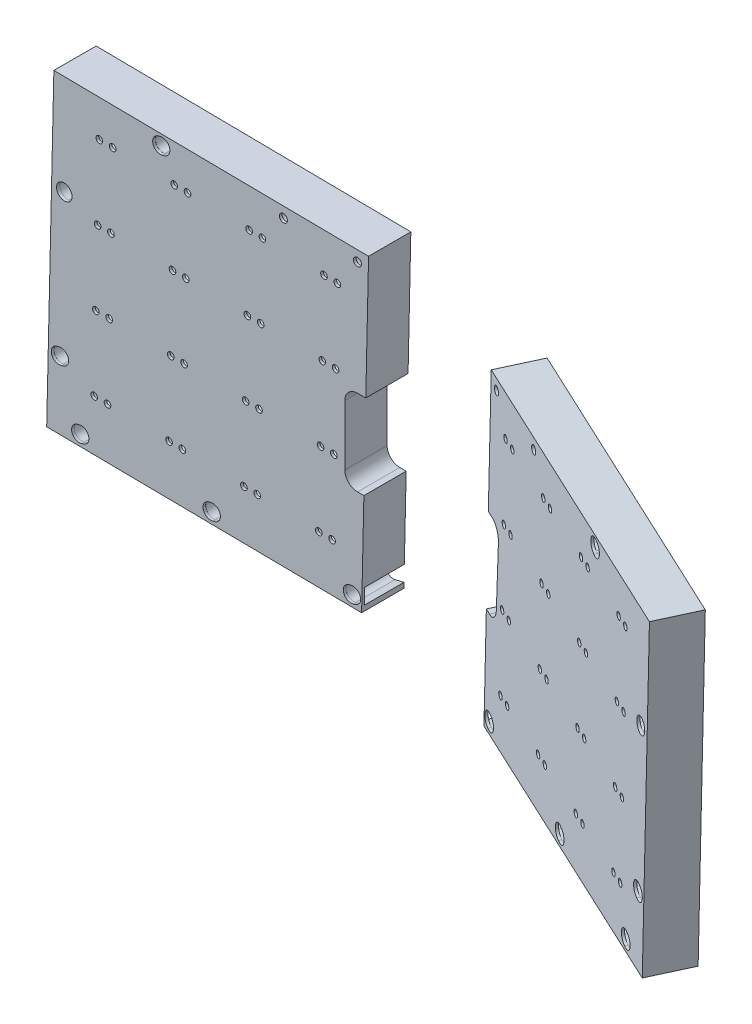
from build123d import *

# Parameters (mm, degrees)
SKETCH1_R           = 2
BOSS_EXTRUDE1_DEPTH = 1.5875
SKETCH5_R           = 5.08
BOSS_EXTRUDE2_DEPTH = 23.8125
SKETCH6_R           = 4.572
SKETCH6_RX          = 4.57299319
SKETCH6_RY          = 4.524389809
SKETCH6_RX_2        = 4.711803069
SKETCH6_RY_2        = 4.489767833
CUT_EXTRUDE1_DEPTH  = 75.812882046
SKETCH7_W           = 12.580625914
SKETCH7_H           = 51.352373787
CUT_EXTRUDE2_DEPTH  = 26.4000007
CUT_EXTRUDE3_DEPTH  = 23.8125
FILLET1_R           = 7.62


with BuildPart() as part:
    # Sketch1 → Boss-Extrude1 (new body)
    with BuildSketch(Plane.XY):
        Polygon((95.228462617, -406.697966446), (99.409870771, -219.138709881), (-89.637655202, -216.96623317), (-93.948938185, -404.523997254), align=None)
        with BuildLine():
            add(Edge.make_bspline(
                [(-78.876809024, -399.474398945), (-77.042879078, -407.178050868), (-71.126983416, -401.699595373), (-65.211087754, -396.221139877), (-72.960913362, -393.995943449), (-80.71073897, -391.770747022), (-78.876809024, -399.474398945)],
                knots=[0, 0, 0, 2.094395102, 2.094395102, 4.188790205, 4.188790205, 6.283185307, 6.283185307, 6.283185307], degree=2, weights=[1, 0.5, 1, 0.5, 1, 0.5, 1]))
        make_face(mode=Mode.SUBTRACT)
        with BuildLine():
            add(Edge.make_bspline(
                [(-91.075107953, -364.992543076), (-89.241178007, -372.696194999), (-83.325282345, -367.217739503), (-77.409386683, -361.739284008), (-85.159212291, -359.51408758), (-92.909037899, -357.288891153), (-91.075107953, -364.992543076)],
                knots=[0, 0, 0, 2.094395102, 2.094395102, 4.188790205, 4.188790205, 6.283185307, 6.283185307, 6.283185307], degree=2, weights=[1, 0.5, 1, 0.5, 1, 0.5, 1]))
        make_face(mode=Mode.SUBTRACT)
        with Locations((-65.421998613, -374.262418552)):
            Circle(SKETCH1_R, mode=Mode.SUBTRACT)
        with Locations((-57.424111279, -374.446261411)):
            Circle(SKETCH1_R, mode=Mode.SUBTRACT)
        with Locations((-20.433882361, -375.296534634)):
            Circle(SKETCH1_R, mode=Mode.SUBTRACT)
        with Locations((-12.435995027, -375.480377492)):
            Circle(SKETCH1_R, mode=Mode.SUBTRACT)
        with Locations((-64.387882531, -329.2743023)):
            Circle(SKETCH1_R, mode=Mode.SUBTRACT)
        with Locations((-56.389995198, -329.458145159)):
            Circle(SKETCH1_R, mode=Mode.SUBTRACT)
        with Locations((-19.399766279, -330.308418381)):
            Circle(SKETCH1_R, mode=Mode.SUBTRACT)
        with Locations((-11.401878945, -330.49226124)):
            Circle(SKETCH1_R, mode=Mode.SUBTRACT)
        with BuildLine():
            add(Edge.make_bspline(
                [(0.072770324, -400.381663515), (1.90670027, -408.085315438), (7.822595932, -402.606859943), (13.738491594, -397.128404447), (5.988665986, -394.90320802), (-1.761159623, -392.678011592), (0.072770324, -400.381663515)],
                knots=[0, 0, 0, 2.094395102, 2.094395102, 4.188790205, 4.188790205, 6.283185307, 6.283185307, 6.283185307], degree=2, weights=[1, 0.5, 1, 0.5, 1, 0.5, 1]))
        make_face(mode=Mode.SUBTRACT)
        with Locations((24.554233892, -376.330650715)):
            Circle(SKETCH1_R, mode=Mode.SUBTRACT)
        with Locations((32.552121226, -376.514493574)):
            Circle(SKETCH1_R, mode=Mode.SUBTRACT)
        with BuildLine():
            add(Edge.make_bspline(
                [(84.347217674, -401.35011985), (86.18114762, -409.053771773), (92.097043282, -403.575316278), (98.012938944, -398.096860782), (90.263113336, -395.871664355), (82.513287727, -393.646467927), (84.347217674, -401.35011985)],
                knots=[0, 0, 0, 2.094395102, 2.094395102, 4.188790205, 4.188790205, 6.283185307, 6.283185307, 6.283185307], degree=2, weights=[1, 0.5, 1, 0.5, 1, 0.5, 1]))
        make_face(mode=Mode.SUBTRACT)
        with Locations((69.542350144, -377.364766796)):
            Circle(SKETCH1_R, mode=Mode.SUBTRACT)
        with Locations((77.540237478, -377.548609655)):
            Circle(SKETCH1_R, mode=Mode.SUBTRACT)
        with Locations((25.588349973, -331.342534463)):
            Circle(SKETCH1_R, mode=Mode.SUBTRACT)
        with Locations((33.586237307, -331.526377322)):
            Circle(SKETCH1_R, mode=Mode.SUBTRACT)
        with Locations((70.576466225, -332.376650544)):
            Circle(SKETCH1_R, mode=Mode.SUBTRACT)
        with Locations((78.574353559, -332.560493403)):
            Circle(SKETCH1_R, mode=Mode.SUBTRACT)
        with Locations((-63.35376645, -284.286186047)):
            Circle(SKETCH1_R, mode=Mode.SUBTRACT)
        with Locations((-55.355879116, -284.470028906)):
            Circle(SKETCH1_R, mode=Mode.SUBTRACT)
        with Locations((-18.365650198, -285.320302129)):
            Circle(SKETCH1_R, mode=Mode.SUBTRACT)
        with Locations((-10.367762864, -285.504144988)):
            Circle(SKETCH1_R, mode=Mode.SUBTRACT)
        with Locations((-62.319650369, -239.298069795)):
            Circle(SKETCH1_R, mode=Mode.SUBTRACT)
        with Locations((-54.321763035, -239.481912654)):
            Circle(SKETCH1_R, mode=Mode.SUBTRACT)
        with BuildLine():
            add(Edge.make_bspline(
                [(-30.054353104, -225.507350134), (-27.583339486, -233.030889441), (-22.213794432, -227.099772034), (-16.844249377, -221.168654626), (-24.684808049, -219.576232727), (-32.525366721, -217.983810827), (-30.054353104, -225.507350134)],
                knots=[0, 0, 0, 2.094395102, 2.094395102, 4.188790205, 4.188790205, 6.283185307, 6.283185307, 6.283185307], degree=2, weights=[1, 0.5, 1, 0.5, 1, 0.5, 1]))
        make_face(mode=Mode.SUBTRACT)
        with Locations((-17.331534116, -240.332185877)):
            Circle(SKETCH1_R, mode=Mode.SUBTRACT)
        with Locations((-9.333646783, -240.516028736)):
            Circle(SKETCH1_R, mode=Mode.SUBTRACT)
        with Locations((26.622466055, -286.35441821)):
            Circle(SKETCH1_R, mode=Mode.SUBTRACT)
        with Locations((34.620353388, -286.538261069)):
            Circle(SKETCH1_R, mode=Mode.SUBTRACT)
        with Locations((71.610582307, -287.388534292)):
            Circle(SKETCH1_R, mode=Mode.SUBTRACT)
        with Locations((79.608469641, -287.572377151)):
            Circle(SKETCH1_R, mode=Mode.SUBTRACT)
        with Locations((27.656582136, -241.366301958)):
            Circle(SKETCH1_R, mode=Mode.SUBTRACT)
        with Locations((35.65446947, -241.550144817)):
            Circle(SKETCH1_R, mode=Mode.SUBTRACT)
        with BuildLine():
            add(Edge.make_bspline(
                [(49.768363525, -226.803251814), (53.038855858, -224.201024518), (49.144615214, -222.663022563), (45.25037457, -221.125020609), (45.874122881, -225.26524986), (46.497871193, -229.405479111), (49.768363525, -226.803251814)],
                knots=[0, 0, 0, 2.094395102, 2.094395102, 4.188790205, 4.188790205, 6.283185307, 6.283185307, 6.283185307], degree=2, weights=[1, 0.5, 1, 0.5, 1, 0.5, 1]))
        make_face(mode=Mode.SUBTRACT)
        with Locations((72.644698388, -242.400418039)):
            Circle(SKETCH1_R, mode=Mode.SUBTRACT)
        with Locations((80.642585722, -242.584260898)):
            Circle(SKETCH1_R, mode=Mode.SUBTRACT)
        with BuildLine():
            add(Edge.make_bspline(
                [(94.257816322, -227.314511084), (97.528308655, -224.712283787), (93.634068011, -223.174281833), (89.739827367, -221.636279879), (90.363575678, -225.77650913), (90.98732399, -229.91673838), (94.257816322, -227.314511084)],
                knots=[0, 0, 0, 2.094395102, 2.094395102, 4.188790205, 4.188790205, 6.283185307, 6.283185307, 6.283185307], degree=2, weights=[1, 0.5, 1, 0.5, 1, 0.5, 1]))
        make_face(mode=Mode.SUBTRACT)
    extrude(amount=-BOSS_EXTRUDE1_DEPTH)

    # Sketch5 → Boss-Extrude2 (add)
    with BuildSketch(Plane(origin=(0, 0, -1.5875), x_dir=(-1, 0, 0), z_dir=(0, 0, -1))):
        Polygon((-95.228462617, -406.697966446), (93.948938185, -404.523997254), (89.637655202, -216.96623317), (-99.409870771, -219.138709881), align=None)
        with BuildLine():
            add(Edge.make_bspline(
                [(-84.347217674, -401.35011985), (-86.18114762, -409.053771773), (-92.097043282, -403.575316278), (-98.012938944, -398.096860782), (-90.263113336, -395.871664355), (-82.513287727, -393.646467927), (-84.347217674, -401.35011985)],
                knots=[0, 0, 0, 2.094395102, 2.094395102, 4.188790205, 4.188790205, 6.283185307, 6.283185307, 6.283185307], degree=2, weights=[1, 0.5, 1, 0.5, 1, 0.5, 1]))
        make_face(mode=Mode.SUBTRACT)
        with BuildLine():
            ThreePointArc((-69.657282283, -372.364766796), (-64.542350144, -377.249834658), (-69.427418006, -382.364766796))
            Line((-69.427418006, -382.364766796), (-77.425305339, -382.548609655))
            ThreePointArc((-77.425305339, -382.548609655), (-82.540237478, -377.663541794), (-77.655169616, -372.548609655))
            Line((-77.655169616, -372.548609655), (-69.657282283, -372.364766796))
        make_face(mode=Mode.SUBTRACT)
        with BuildLine():
            add(Edge.make_bspline(
                [(-0.072770324, -400.381663515), (-1.90670027, -408.085315438), (-7.822595932, -402.606859943), (-13.738491594, -397.128404447), (-5.988665986, -394.90320802), (1.761159623, -392.678011592), (-0.072770324, -400.381663515)],
                knots=[0, 0, 0, 2.094395102, 2.094395102, 4.188790205, 4.188790205, 6.283185307, 6.283185307, 6.283185307], degree=2, weights=[1, 0.5, 1, 0.5, 1, 0.5, 1]))
        make_face(mode=Mode.SUBTRACT)
        with BuildLine():
            ThreePointArc((-24.66916603, -371.330650715), (-19.554233892, -376.215718576), (-24.439301753, -381.330650715))
            Line((-24.439301753, -381.330650715), (-32.437189087, -381.514493574))
            ThreePointArc((-32.437189087, -381.514493574), (-37.552121226, -376.629425712), (-32.667053364, -371.514493574))
            Line((-32.667053364, -371.514493574), (-24.66916603, -371.330650715))
        make_face(mode=Mode.SUBTRACT)
        with BuildLine():
            ThreePointArc((-70.691398364, -327.376650544), (-65.576466225, -332.261718406), (-70.461534087, -337.376650544))
            Line((-70.461534087, -337.376650544), (-78.459421421, -337.560493403))
            ThreePointArc((-78.459421421, -337.560493403), (-83.574353559, -332.675425541), (-78.689285698, -327.560493403))
            Line((-78.689285698, -327.560493403), (-70.691398364, -327.376650544))
        make_face(mode=Mode.SUBTRACT)
        with BuildLine():
            ThreePointArc((-25.703282112, -326.342534463), (-20.588349973, -331.227602324), (-25.473417835, -336.342534463))
            Line((-25.473417835, -336.342534463), (-33.471305168, -336.526377322))
            ThreePointArc((-33.471305168, -336.526377322), (-38.586237307, -331.64130946), (-33.701169445, -326.526377322))
            Line((-33.701169445, -326.526377322), (-25.703282112, -326.342534463))
        make_face(mode=Mode.SUBTRACT)
        with BuildLine():
            ThreePointArc((20.318950222, -370.296534634), (25.433882361, -375.181602495), (20.548814499, -380.296534634))
            Line((20.548814499, -380.296534634), (12.550927165, -380.480377492))
            ThreePointArc((12.550927165, -380.480377492), (7.435995027, -375.595309631), (12.321062888, -370.480377492))
            Line((12.321062888, -370.480377492), (20.318950222, -370.296534634))
        make_face(mode=Mode.SUBTRACT)
        with BuildLine():
            add(Edge.make_bspline(
                [(78.876809024, -399.474398945), (77.042879078, -407.178050868), (71.126983416, -401.699595373), (65.211087754, -396.221139877), (72.960913362, -393.995943449), (80.71073897, -391.770747022), (78.876809024, -399.474398945)],
                knots=[0, 0, 0, 2.094395102, 2.094395102, 4.188790205, 4.188790205, 6.283185307, 6.283185307, 6.283185307], degree=2, weights=[1, 0.5, 1, 0.5, 1, 0.5, 1]))
        make_face(mode=Mode.SUBTRACT)
        with BuildLine():
            ThreePointArc((65.307066474, -369.262418552), (70.421998613, -374.147486414), (65.536930751, -379.262418552))
            Line((65.536930751, -379.262418552), (57.539043418, -379.446261411))
            ThreePointArc((57.539043418, -379.446261411), (52.424111279, -374.561193549), (57.309179141, -369.446261411))
            Line((57.309179141, -369.446261411), (65.307066474, -369.262418552))
        make_face(mode=Mode.SUBTRACT)
        with BuildLine():
            add(Edge.make_bspline(
                [(91.075107953, -364.992543076), (89.241178007, -372.696194999), (83.325282345, -367.217739503), (77.409386683, -361.739284008), (85.159212291, -359.51408758), (92.909037899, -357.288891153), (91.075107953, -364.992543076)],
                knots=[0, 0, 0, 2.094395102, 2.094395102, 4.188790205, 4.188790205, 6.283185307, 6.283185307, 6.283185307], degree=2, weights=[1, 0.5, 1, 0.5, 1, 0.5, 1]))
        make_face(mode=Mode.SUBTRACT)
        with BuildLine():
            ThreePointArc((19.284826552, -325.308088244), (24.400096416, -330.193478654), (19.514706006, -335.308748518))
            Line((19.514706006, -335.308748518), (11.516818673, -335.492591377))
            ThreePointArc((11.516818673, -335.492591377), (6.401548809, -330.607200967), (11.286939218, -325.491931103))
            Line((11.286939218, -325.491931103), (19.284826552, -325.308088244))
        make_face(mode=Mode.SUBTRACT)
        with BuildLine():
            ThreePointArc((64.272942804, -324.273972163), (69.388212668, -329.159362573), (64.502822259, -334.274632437))
            Line((64.502822259, -334.274632437), (56.504934925, -334.458475296))
            ThreePointArc((56.504934925, -334.458475296), (51.389665061, -329.573084886), (56.275055471, -324.457815022))
            Line((56.275055471, -324.457815022), (64.272942804, -324.273972163))
        make_face(mode=Mode.SUBTRACT)
        with BuildLine():
            ThreePointArc((-71.725514445, -282.388534292), (-66.610582307, -287.273602153), (-71.495650168, -292.388534292))
            Line((-71.495650168, -292.388534292), (-79.493537502, -292.572377151))
            ThreePointArc((-79.493537502, -292.572377151), (-84.608469641, -287.687309289), (-79.723401779, -282.572377151))
            Line((-79.723401779, -282.572377151), (-71.725514445, -282.388534292))
        make_face(mode=Mode.SUBTRACT)
        with BuildLine():
            ThreePointArc((-26.737405782, -281.354088074), (-21.622135918, -286.239478483), (-26.507526327, -291.354748347))
            Line((-26.507526327, -291.354748347), (-34.505413661, -291.538591206))
            ThreePointArc((-34.505413661, -291.538591206), (-39.620683525, -286.653200796), (-34.735293115, -281.537930932))
            Line((-34.735293115, -281.537930932), (-26.737405782, -281.354088074))
        make_face(mode=Mode.SUBTRACT)
        with BuildLine():
            ThreePointArc((-72.759630527, -237.400418039), (-67.644698388, -242.285485901), (-72.52976625, -247.400418039))
            Line((-72.52976625, -247.400418039), (-80.527653584, -247.584260898))
            ThreePointArc((-80.527653584, -247.584260898), (-85.642585722, -242.699193037), (-80.757517861, -237.584260898))
            Line((-80.757517861, -237.584260898), (-72.759630527, -237.400418039))
        make_face(mode=Mode.SUBTRACT)
        with Locations((-92.730228243, -225.421519223)):
            Circle(SKETCH5_R, mode=Mode.SUBTRACT)
        with BuildLine():
            ThreePointArc((-27.771514274, -236.366301958), (-22.656582136, -241.25136982), (-27.541649998, -246.366301958))
            Line((-27.541649998, -246.366301958), (-35.539537331, -246.550144817))
            ThreePointArc((-35.539537331, -246.550144817), (-40.65446947, -241.665076955), (-35.769401608, -236.550144817))
            Line((-35.769401608, -236.550144817), (-27.771514274, -236.366301958))
        make_face(mode=Mode.SUBTRACT)
        with Locations((-48.240775446, -224.910259953)):
            Circle(SKETCH5_R, mode=Mode.SUBTRACT)
        with BuildLine():
            ThreePointArc((18.250718059, -280.320302129), (23.365650198, -285.20536999), (18.480582336, -290.320302129))
            Line((18.480582336, -290.320302129), (10.482695002, -290.504144988))
            ThreePointArc((10.482695002, -290.504144988), (5.367762864, -285.619077126), (10.252830725, -280.504144988))
            Line((10.252830725, -280.504144988), (18.250718059, -280.320302129))
        make_face(mode=Mode.SUBTRACT)
        with BuildLine():
            ThreePointArc((55.470811255, -289.470028906), (50.355879116, -284.584961045), (55.240946978, -279.470028906))
            Line((55.240946978, -279.470028906), (63.238834312, -279.286186047))
            ThreePointArc((63.238834312, -279.286186047), (68.35376645, -284.171253909), (63.468698588, -289.286186047))
            Line((63.468698588, -289.286186047), (55.470811255, -289.470028906))
        make_face(mode=Mode.SUBTRACT)
        with BuildLine():
            ThreePointArc((17.216601978, -235.332185877), (22.331534116, -240.217253738), (17.446466255, -245.332185877))
            Line((17.446466255, -245.332185877), (9.448578921, -245.516028736))
            ThreePointArc((9.448578921, -245.516028736), (4.333646783, -240.630960874), (9.218714644, -235.516028736))
            Line((9.218714644, -235.516028736), (17.216601978, -235.332185877))
        make_face(mode=Mode.SUBTRACT)
        with BuildLine():
            add(Edge.make_bspline(
                [(30.054353104, -225.507350134), (27.583339486, -233.030889441), (22.213794432, -227.099772034), (16.844249377, -221.168654626), (24.684808049, -219.576232727), (32.525366721, -217.983810827), (30.054353104, -225.507350134)],
                knots=[0, 0, 0, 2.094395102, 2.094395102, 4.188790205, 4.188790205, 6.283185307, 6.283185307, 6.283185307], degree=2, weights=[1, 0.5, 1, 0.5, 1, 0.5, 1]))
        make_face(mode=Mode.SUBTRACT)
        with BuildLine():
            ThreePointArc((62.204710641, -234.297739658), (67.319980505, -239.183130068), (62.434590096, -244.298399932))
            Line((62.434590096, -244.298399932), (54.436702762, -244.482242791))
            ThreePointArc((54.436702762, -244.482242791), (49.321432898, -239.596852381), (54.206823308, -234.481582517))
            Line((54.206823308, -234.481582517), (62.204710641, -234.297739658))
        make_face(mode=Mode.SUBTRACT)
        with BuildLine():
            add(Edge.make_bspline(
                [(78.876809024, -399.474398945), (77.042879078, -407.178050868), (71.126983416, -401.699595373), (65.211087754, -396.221139877), (72.960913362, -393.995943449), (80.71073897, -391.770747022), (78.876809024, -399.474398945)],
                knots=[0, 0, 0, 2.094395102, 2.094395102, 4.188790205, 4.188790205, 6.283185307, 6.283185307, 6.283185307], degree=2, weights=[1, 0.5, 1, 0.5, 1, 0.5, 1]))
        make_face()
        with BuildLine():
            add(Edge.make_bspline(
                [(91.075107953, -364.992543076), (89.241178007, -372.696194999), (83.325282345, -367.217739503), (77.409386683, -361.739284008), (85.159212291, -359.51408758), (92.909037899, -357.288891153), (91.075107953, -364.992543076)],
                knots=[0, 0, 0, 2.094395102, 2.094395102, 4.188790205, 4.188790205, 6.283185307, 6.283185307, 6.283185307], degree=2, weights=[1, 0.5, 1, 0.5, 1, 0.5, 1]))
        make_face()
        with BuildLine():
            add(Edge.make_bspline(
                [(-0.072770324, -400.381663515), (-1.90670027, -408.085315438), (-7.822595932, -402.606859943), (-13.738491594, -397.128404447), (-5.988665986, -394.90320802), (1.761159623, -392.678011592), (-0.072770324, -400.381663515)],
                knots=[0, 0, 0, 2.094395102, 2.094395102, 4.188790205, 4.188790205, 6.283185307, 6.283185307, 6.283185307], degree=2, weights=[1, 0.5, 1, 0.5, 1, 0.5, 1]))
        make_face()
        with BuildLine():
            add(Edge.make_bspline(
                [(-84.347217674, -401.35011985), (-86.18114762, -409.053771773), (-92.097043282, -403.575316278), (-98.012938944, -398.096860782), (-90.263113336, -395.871664355), (-82.513287727, -393.646467927), (-84.347217674, -401.35011985)],
                knots=[0, 0, 0, 2.094395102, 2.094395102, 4.188790205, 4.188790205, 6.283185307, 6.283185307, 6.283185307], degree=2, weights=[1, 0.5, 1, 0.5, 1, 0.5, 1]))
        make_face()
        with BuildLine():
            add(Edge.make_bspline(
                [(30.054353104, -225.507350134), (27.583339486, -233.030889441), (22.213794432, -227.099772034), (16.844249377, -221.168654626), (24.684808049, -219.576232727), (32.525366721, -217.983810827), (30.054353104, -225.507350134)],
                knots=[0, 0, 0, 2.094395102, 2.094395102, 4.188790205, 4.188790205, 6.283185307, 6.283185307, 6.283185307], degree=2, weights=[1, 0.5, 1, 0.5, 1, 0.5, 1]))
        make_face()
    extrude(amount=BOSS_EXTRUDE2_DEPTH)

    # Sketch6 → Cut-Extrude1 (cut, through all)
    with BuildSketch(Plane(origin=(-8.400312384, -1.999776806, 39.033239435), x_dir=(-0.977673714, 0.010751357, -0.209853561), z_dir=(0.210128791, 0.050023221, -0.976393142))):
        with Locations((79.62642635, -363.175643293)):
            Circle(SKETCH6_R)
        with Locations((67.329743395, -397.612334312)):
            Circle(SKETCH6_R)
        with Locations((-9.866939397, -398.518410533)):
            Circle(SKETCH6_R)
        with Locations((-92.270263562, -399.48559837)):
            Circle(SKETCH6_R)
        with Locations(Location((21.620065133, -223.511811904), (0, 0, -97.567725492))):
            Ellipse(SKETCH6_RX, SKETCH6_RY)
        with Locations(Location((78.560397087, -276.684678671), (0, 0, 53.520699818))):
            Ellipse(SKETCH6_RX_2, SKETCH6_RY_2)
    extrude(amount=CUT_EXTRUDE1_DEPTH, mode=Mode.SUBTRACT)

    # Sketch7 → Cut-Extrude2 (cut, through all)
    with BuildSketch(Plane(origin=(0, 0, -25.4), x_dir=(-1, 0, 0), z_dir=(0, 0, -1))):
        with Locations((-91.457481674, -319.368194066)):
            Rectangle(SKETCH7_W, SKETCH7_H)
    extrude(amount=-CUT_EXTRUDE2_DEPTH, mode=Mode.SUBTRACT)

    # Sketch8 → Cut-Extrude3 (cut)
    with BuildSketch(Plane(origin=(0, 0, -25.4), x_dir=(-1, 0, 0), z_dir=(0, 0, -1))):
        with BuildLine():
            Line((-94.368420644, -394.18668603), (-87.826060845, -395.744158988))
            ThreePointArc((-87.826060845, -395.744158988), (-84.380916925, -401.342097413), (-89.978855349, -404.787241333))
            Line((-89.978855349, -404.787241333), (-96.521215147, -403.229768375))
            ThreePointArc((-96.521215147, -403.229768375), (-99.966359068, -397.63182995), (-94.368420644, -394.18668603))
        make_face()
        with BuildLine():
            Line((-5.697970133, -403.791741937), (-12.240329931, -402.234268978))
            ThreePointArc((-12.240329931, -402.234268978), (-15.664868657, -396.669811481), (-10.10041116, -393.245272756))
            Line((-10.10041116, -393.245272756), (-3.558051361, -394.802745715))
            ThreePointArc((-3.558051361, -394.802745715), (-0.133512636, -400.367203212), (-5.697970133, -403.791741937))
        make_face()
        with BuildLine():
            Line((68.881382247, -392.202689005), (75.423742045, -393.760161964))
            ThreePointArc((75.423742045, -393.760161964), (78.951385892, -399.4921527), (73.219395156, -403.019796547))
            Line((73.219395156, -403.019796547), (66.677035358, -401.462323588))
            ThreePointArc((66.677035358, -401.462323588), (63.149391511, -395.730332852), (68.881382247, -392.202689005))
        make_face()
        with BuildLine():
            Line((81.045435716, -357.864685469), (87.587795515, -359.422158428))
            ThreePointArc((87.587795515, -359.422158428), (91.005832488, -364.976051371), (85.451939545, -368.394088345))
            Line((85.451939545, -368.394088345), (78.909579746, -366.836615386))
            ThreePointArc((78.909579746, -366.836615386), (75.491542772, -361.282722443), (81.045435716, -357.864685469))
        make_face()
        with BuildLine():
            Line((20.160903535, -218.083419516), (26.703263333, -219.640892475))
            ThreePointArc((26.703263333, -219.640892475), (30.071211018, -225.113396437), (24.598707056, -228.481344122))
            Line((24.598707056, -228.481344122), (18.056347257, -226.923871163))
            ThreePointArc((18.056347257, -226.923871163), (14.688399573, -221.451367201), (20.160903535, -218.083419516))
        make_face()
        with BuildLine():
            Line((79.017758337, -271.196965988), (84.484072116, -272.498275632))
            ThreePointArc((84.484072116, -272.498275632), (87.950354471, -278.130561433), (82.31806867, -281.596843788))
            Line((82.31806867, -281.596843788), (76.851754891, -280.295534145))
            ThreePointArc((76.851754891, -280.295534145), (73.385472535, -274.663248344), (79.017758337, -271.196965988))
        make_face()
    extrude(amount=-CUT_EXTRUDE3_DEPTH, mode=Mode.SUBTRACT)

    # Fillet1
    fillet1_edges = [part.edges().sort_by_distance(p)[0] for p in [
        (85.167168717, -293.692007172, -12.7),
        (85.167168717, -345.044380959, -12.7),
    ]]
    fillet(fillet1_edges, radius=FILLET1_R)


with BuildPart() as body_2:
    # Mirror2: mirrored copy
    add(part.part.mirror(Plane(origin=(146.705913717, -3.372244878, 31.399693812), x_dir=(-0.20918335, 0.004808378, 0.977864615), z_dir=(-0.977606377, 0.022471678, -0.209238606))))


solid = Compound([part.part, body_2.part])
